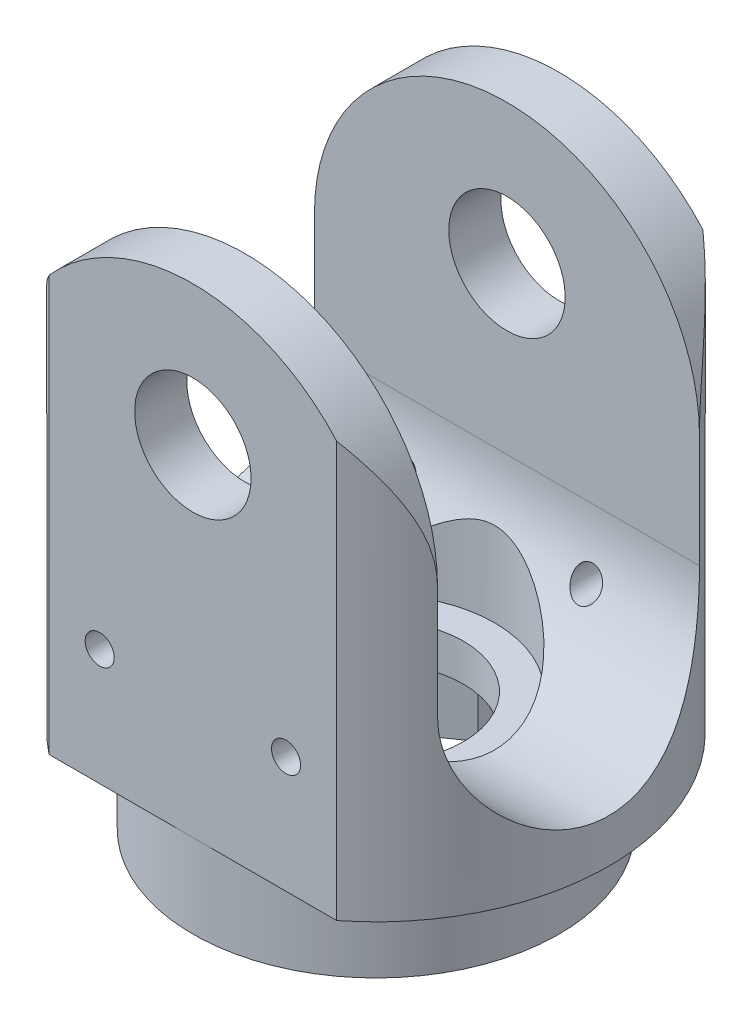
from build123d import *

# Parameters (mm, degrees)
SKETCH1_R                = 12.7
BOSS_EXTRUDE1_DEPTH      = 15.367
BOSS_EXTRUDE1_DEPTH_BACK = 15.367
SKETCH4_W                = 25.4
SKETCH4_H                = 30.734
CUT_EXTRUDE2_DEPTH       = 3.71145
SKETCH5_W                = 14.2875
SKETCH5_H                = 16.637
CUT_EXTRUDE3_DEPTH       = 13.7
CUT_EXTRUDE3_DEPTH_BACK  = 13.7
CUT_EXTRUDE4_DEPTH       = 20.9771001
SKETCH7_R                = 4.7625
CUT_EXTRUDE5_DEPTH       = 31.7340001
SKETCH9_R                = 17.852773039
SKETCH9_R_2              = 9.9822
CUT_EXTRUDE6_DEPTH       = 4.572
SKETCH10_R               = 6.477
CUT_EXTRUDE7_DEPTH       = 24.257
SKETCH11_R               = 3.175
CUT_EXTRUDE8_DEPTH       = 20.9771001
SKETCH12_R               = 0.79375
CUT_EXTRUDE9_DEPTH       = 1.0000001
CUT_EXTRUDE9_DEPTH_BACK  = 20.9771001
SKETCH15_R               = 4.7625
CUT_EXTRUDE12_DEPTH      = 4.445
SKETCH16_R               = 1.5875
CUT_EXTRUDE13_DEPTH      = 4.445


with BuildPart() as part:
    # Sketch1 → Boss-Extrude1 (new body, two sides)
    with BuildSketch(Plane(origin=(0, 0, 0), x_dir=(1, 0, 0), z_dir=(0, 1, 0))) as boss_extrude1_sk:
        Circle(SKETCH1_R)
    extrude(amount=BOSS_EXTRUDE1_DEPTH)
    extrude(boss_extrude1_sk.sketch, amount=-BOSS_EXTRUDE1_DEPTH_BACK)

    # Sketch4 → Cut-Extrude2 (cut, through all)
    with BuildSketch(Plane.XY.offset(9.98855)):
        Rectangle(SKETCH4_W, SKETCH4_H)
    cut_extrude2 = extrude(amount=CUT_EXTRUDE2_DEPTH, mode=Mode.SUBTRACT)

    # Mirror2: Cut-Extrude2 across plane
    add(cut_extrude2.mirror(Plane.XY), mode=Mode.SUBTRACT)

    # Sketch5 → Cut-Extrude3 (cut, two sides)
    with BuildSketch(Plane(origin=(0, 0, 0), x_dir=(0, 0, -1), z_dir=(1, 0, 0))) as cut_extrude3_sk:
        with Locations((0, 7.0485)):
            Rectangle(SKETCH5_W, SKETCH5_H)
        with BuildLine():
            Line((7.14375, -1.27), (-7.14375, -1.27))
            ThreePointArc((-7.14375, -1.27), (0, -8.41375), (7.14375, -1.27))
        make_face()
    extrude(amount=CUT_EXTRUDE3_DEPTH, mode=Mode.SUBTRACT)
    extrude(cut_extrude3_sk.sketch, amount=-CUT_EXTRUDE3_DEPTH_BACK, mode=Mode.SUBTRACT)

    # Sketch6 → Cut-Extrude4 (cut, through all)
    with BuildSketch(Plane.XY.offset(9.98855)):
        with BuildLine():
            ThreePointArc((7.843396515, 11.847950137), (9.813665145, 8.601547837), (10.50036, 4.86664))
            Line((10.50036, 4.86664), (14.849727138, 4.86664))
            ThreePointArc((14.849727138, 4.86664), (0, 19.716367138), (-14.849727138, 4.86664))
            Line((-14.849727138, 4.86664), (-10.50036, 4.86664))
            ThreePointArc((-10.50036, 4.86664), (-9.813665145, 8.601547837), (-7.843396515, 11.847950137))
            Line((-7.843396515, 11.847950137), (-7.843396515, 15.367))
            Line((-7.843396515, 15.367), (0, 15.367))
            Line((0, 15.367), (7.843396515, 15.367))
            Line((7.843396515, 15.367), (7.843396515, 11.847950137))
        make_face()
        with BuildLine():
            ThreePointArc((-7.843396515, 11.847950137), (-4.298330514, 14.446927831), (0, 15.367))
            Line((0, 15.367), (-7.843396515, 15.367))
            Line((-7.843396515, 15.367), (-7.843396515, 11.847950137))
        make_face()
        with BuildLine():
            ThreePointArc((0, 15.367), (4.298330514, 14.446927831), (7.843396515, 11.847950137))
            Line((7.843396515, 11.847950137), (7.843396515, 15.367))
            Line((7.843396515, 15.367), (0, 15.367))
        make_face()
    extrude(amount=-CUT_EXTRUDE4_DEPTH, mode=Mode.SUBTRACT)

    # Sketch7 → Cut-Extrude5 (cut, through all)
    with BuildSketch(Plane.XZ.offset(15.367)):
        Circle(SKETCH7_R)
    extrude(amount=-CUT_EXTRUDE5_DEPTH, mode=Mode.SUBTRACT)

    # Sketch9 → Cut-Extrude6 (cut)
    with BuildSketch(Plane.XZ.offset(15.367)):
        Circle(SKETCH9_R)
        Circle(SKETCH9_R_2, mode=Mode.SUBTRACT)
    extrude(amount=-CUT_EXTRUDE6_DEPTH, mode=Mode.SUBTRACT)

    # Sketch10 → Cut-Extrude7 (cut)
    with BuildSketch(Plane(origin=(0, 15.367, 0), x_dir=(1, 0, 0), z_dir=(0, 1, 0))):
        Circle(SKETCH10_R)
    extrude(amount=-CUT_EXTRUDE7_DEPTH, mode=Mode.SUBTRACT)

    # Sketch11 → Cut-Extrude8 (cut, through all)
    with BuildSketch(Plane.XY.offset(9.98855)):
        with Locations((0, 7.747)):
            Circle(SKETCH11_R)
    extrude(amount=-CUT_EXTRUDE8_DEPTH, mode=Mode.SUBTRACT)

    # Sketch12 → Cut-Extrude9 (cut, two sides)
    with BuildSketch(Plane(origin=(0, 0, -9.98855), x_dir=(-1, 0, 0), z_dir=(0, 0, -1))) as cut_extrude9_sk:
        with Locations((5.081146515, -4.445)):
            Circle(SKETCH12_R)
        with Locations((-5.081146515, -4.445)):
            Circle(SKETCH12_R)
    extrude(amount=CUT_EXTRUDE9_DEPTH, mode=Mode.SUBTRACT)
    extrude(cut_extrude9_sk.sketch, amount=-CUT_EXTRUDE9_DEPTH_BACK, mode=Mode.SUBTRACT)

    # Sketch15 → Cut-Extrude12 (cut)
    with BuildSketch(Plane.XZ.offset(15.367)):
        with BuildLine():
            ThreePointArc((8.001, 0), (-1.271072049, 7.899390916), (-7.597144444, -2.509860017))
            Line((-7.597144444, -2.509860017), (0.239879494, -7.997403255))
            ThreePointArc((0.239879494, -7.997403255), (5.741745241, -5.572105758), (8.001, 0))
        make_face()
        Circle(SKETCH15_R, mode=Mode.SUBTRACT)
    extrude(amount=-CUT_EXTRUDE12_DEPTH, mode=Mode.SUBTRACT)

    # Sketch16 → Cut-Extrude13 (cut)
    with BuildSketch(Plane.XZ.offset(15.367)):
        with Locations((-6.873606877, -2.270825729)):
            Circle(SKETCH16_R)
        with Locations((0.217023554, -7.235403255)):
            Circle(SKETCH16_R)
    extrude(amount=-CUT_EXTRUDE13_DEPTH, mode=Mode.SUBTRACT)


solid = part.part
